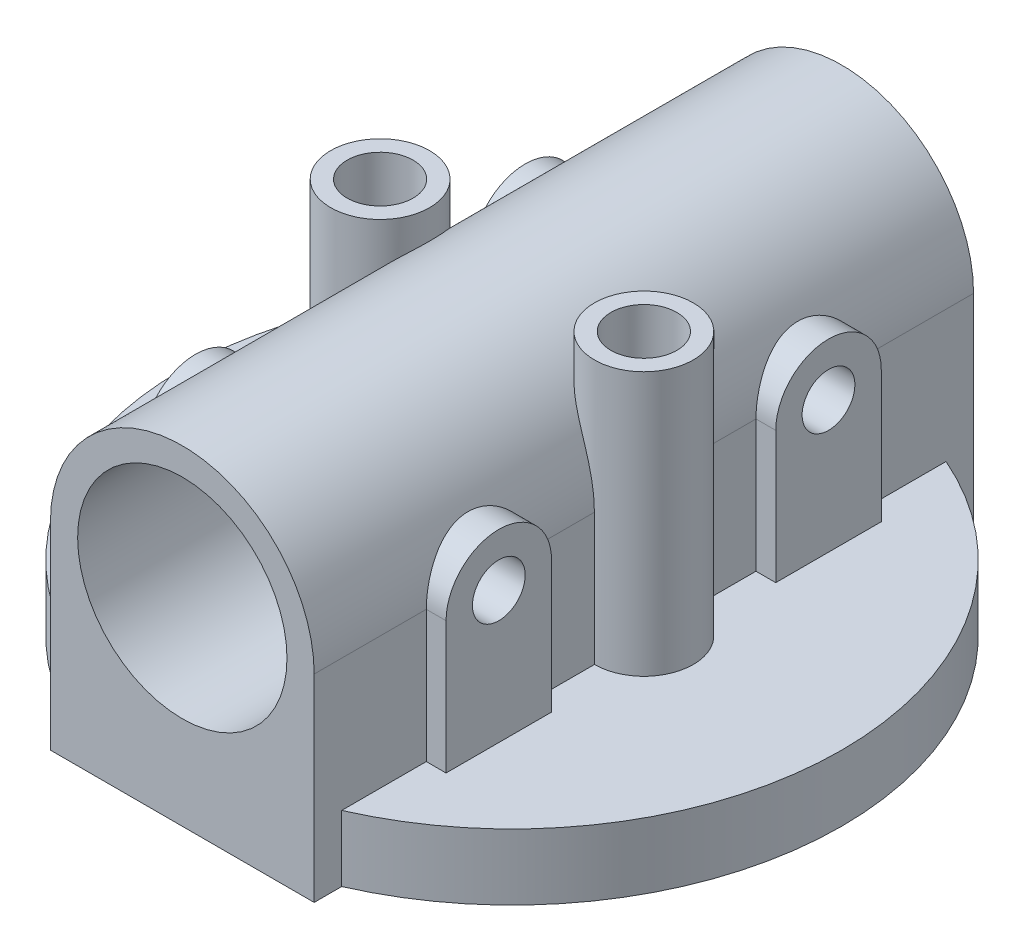
from build123d import *

# Parameters (mm, degrees)
SKETCH1_R               = 15.875
EXTRUDE1_DEPTH          = 50
SKETCH2_R               = 50
EXTRUDE2_DEPTH          = 10
SKETCH2_3_R             = 7.5
EXTRUDE3_DEPTH          = 50.001
EXTRUDE4_DEPTH          = 3
EXTRUDE4_DEPTH_BACK     = 43
SKETCH6_4_R             = 4
CUT_EXTRUDE1_DEPTH      = 31
CUT_EXTRUDE1_DEPTH_BACK = 71
CUT_EXTRUDE2_DEPTH      = 51.0010001
SKETCH1_3_R             = 15.875
CUT_EXTRUDE3_DEPTH      = 51.0000001
CUT_EXTRUDE3_DEPTH_BACK = 51.0000001


with BuildPart() as part:
    # Sketch1 → Extrude1 (new body, symmetric)
    with BuildSketch(Plane.XY):
        with BuildLine():
            Line((20, 0), (20, 30))
            ThreePointArc((20, 30), (0, 50), (-20, 30))
            Line((-20, 30), (-20, 0))
            Line((-20, 0), (20, 0))
        make_face()
        with Locations((0, 30)):
            Circle(SKETCH1_R, mode=Mode.SUBTRACT)
        with Locations((0, 30)):
            Circle(SKETCH1_R)
    extrude(amount=EXTRUDE1_DEPTH, both=True)

    # Sketch2 → Extrude2 (add)
    with BuildSketch(Plane.XZ):
        Circle(SKETCH2_R)
    extrude(amount=-EXTRUDE2_DEPTH)

    # Sketch2_3 → Extrude3 (add)
    with BuildSketch(Plane.XZ):
        with Locations(Location((-20, 0, 0), (0, 0, 270))):  # turned: the seam where the file's is
            Circle(SKETCH2_3_R)
        with Locations(Location((20, 0, 0), (0, 0, 270))):  # turned: the seam where the file's is
            Circle(SKETCH2_3_R)
    extrude(amount=-EXTRUDE3_DEPTH)

    # Sketch3 → Extrude4 (add, two sides)
    with BuildSketch(Plane(origin=(20, 0, 0), x_dir=(0, 0, -1), z_dir=(1, 0, 0))) as extrude4_sk:
        with BuildLine():
            Line((-33, 30), (-33, 10))
            Line((-33, 10), (-17, 10))
            Line((-17, 10), (-17, 30))
            ThreePointArc((-17, 30), (-25, 38), (-33, 30))
        make_face()
        with BuildLine():
            Line((17, 30), (17, 10))
            Line((17, 10), (33, 10))
            Line((33, 10), (33, 30))
            ThreePointArc((33, 30), (25, 38), (17, 30))
        make_face()
    extrude(amount=EXTRUDE4_DEPTH)
    extrude(extrude4_sk.sketch, amount=-EXTRUDE4_DEPTH_BACK)

    # Sketch6_4 → Cut-Extrude1 (cut, two sides)
    with BuildSketch(Plane(origin=(20, 0, 0), x_dir=(0, 0, -1), z_dir=(1, 0, 0))) as cut_extrude1_sk:
        with Locations(Location((-25, 30, 0), (0, 0, 90))):  # turned: the seam where the file's is
            Circle(SKETCH6_4_R)
        with Locations(Location((25, 30, 0), (0, 0, 90))):  # turned: the seam where the file's is
            Circle(SKETCH6_4_R)
    extrude(amount=CUT_EXTRUDE1_DEPTH, mode=Mode.SUBTRACT)
    extrude(cut_extrude1_sk.sketch, amount=-CUT_EXTRUDE1_DEPTH_BACK, mode=Mode.SUBTRACT)

    # Sketch2_4 → Cut-Extrude2 (cut, through all)
    with BuildSketch(Plane.XZ):
        with BuildLine():
            Line((20, -5), (20, 5))
            ThreePointArc((20, 5), (15, 0), (20, -5))
        make_face()
        with BuildLine():
            ThreePointArc((25, 0), (23.535533906, 3.535533906), (20, 5))
            Line((20, 5), (20, -5))
            ThreePointArc((20, -5), (23.535533906, -3.535533906), (25, 0))
        make_face()
        with BuildLine():
            Line((20, -5), (20, 5))
            ThreePointArc((20, 5), (15, 0), (20, -5))
        make_face()
        with BuildLine():
            ThreePointArc((25, 0), (23.535533906, 3.535533906), (20, 5))
            Line((20, 5), (20, -5))
            ThreePointArc((20, -5), (23.535533906, -3.535533906), (25, 0))
        make_face()
        with BuildLine():
            Line((-20, -5), (-20, 5))
            ThreePointArc((-20, 5), (-25, 0), (-20, -5))
        make_face()
        with BuildLine():
            ThreePointArc((-15, 0), (-16.464466094, 3.535533906), (-20, 5))
            Line((-20, 5), (-20, -5))
            ThreePointArc((-20, -5), (-16.464466094, -3.535533906), (-15, 0))
        make_face()
        with BuildLine():
            Line((-20, -5), (-20, 5))
            ThreePointArc((-20, 5), (-25, 0), (-20, -5))
        make_face()
        with BuildLine():
            ThreePointArc((-15, 0), (-16.464466094, 3.535533906), (-20, 5))
            Line((-20, 5), (-20, -5))
            ThreePointArc((-20, -5), (-16.464466094, -3.535533906), (-15, 0))
        make_face()
    extrude(amount=-CUT_EXTRUDE2_DEPTH, mode=Mode.SUBTRACT)

    # Sketch1_3 → Cut-Extrude3 (cut, two sides)
    with BuildSketch(Plane.XY) as cut_extrude3_sk:
        with Locations((0, 30)):
            Circle(SKETCH1_3_R)
    extrude(amount=CUT_EXTRUDE3_DEPTH, mode=Mode.SUBTRACT)
    extrude(cut_extrude3_sk.sketch, amount=-CUT_EXTRUDE3_DEPTH_BACK, mode=Mode.SUBTRACT)


solid = part.part
